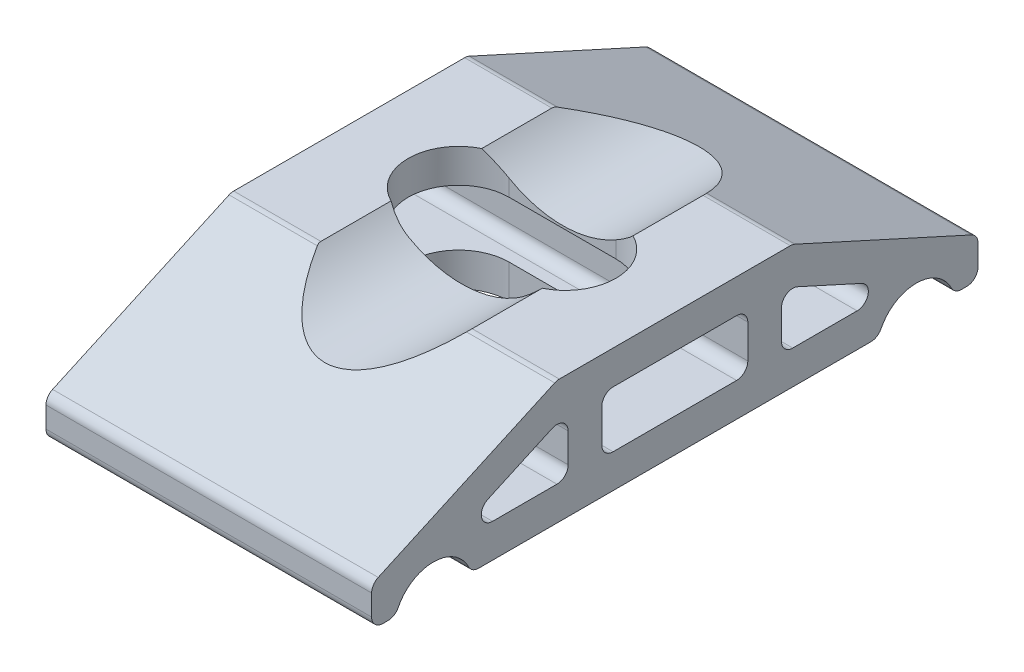
from build123d import *

# Parameters (mm, degrees)
EXTRUSION1_DEPTH             = 14.5
ENL_V_MAT_EXTRU_1_DEPTH      = 12
ESQUISSE3_R                  = 9.5
ENL_V_MAT_EXTRU_4_DEPTH      = 28
ENL_V_MAT_EXTRU_4_DEPTH_BACK = 28


with BuildPart() as part:
    # Esquisse1 → Extrusion1 (new body, symmetric)
    with BuildSketch(Plane(origin=(0, 0, 0), x_dir=(0, 0, -1), z_dir=(1, 0, 0))):
        with BuildLine():
            Line((-27, 1), (-27, 2.85608673))
            ThreePointArc((-27, 2.85608673), (-26.840774329, 3.397472477), (-26.413802944, 3.766453207))
            Line((-26.413802944, 3.766453207), (-10.69719375, 10.910366477))
            ThreePointArc((-10.69719375, 10.910366477), (-10.495090501, 10.977334763), (-10.283390805, 11))
            Line((-10.283390805, 11), (10.283390805, 11))
            ThreePointArc((10.283390805, 11), (10.495090501, 10.977334763), (10.69719375, 10.910366477))
            Line((10.69719375, 10.910366477), (26.413802944, 3.766453207))
            ThreePointArc((26.413802944, 3.766453207), (26.840774329, 3.397472477), (27, 2.85608673))
            Line((27, 2.85608673), (27, 1))
            ThreePointArc((27, 1), (26.707106781, 0.292893219), (26, 0))
            Line((26, 0), (25.531128874, 0))
            ThreePointArc((25.531128874, 0), (25.004082597, 0.150163414), (24.635322458, 0.555555556))
            ThreePointArc((24.635322458, 0.555555556), (21.5, 2.5), (18.364677542, 0.555555556))
            ThreePointArc((18.364677542, 0.555555556), (17.995917403, 0.150163414), (17.468871126, 0))
            Line((17.468871126, 0), (-17.468871126, 0))
            ThreePointArc((-17.468871126, 0), (-17.995917403, 0.150163414), (-18.364677542, 0.555555556))
            ThreePointArc((-18.364677542, 0.555555556), (-21.5, 2.5), (-24.635322458, 0.555555556))
            ThreePointArc((-24.635322458, 0.555555556), (-25.004082597, 0.150163414), (-25.531128874, 0))
            Line((-25.531128874, 0), (-26, 0))
            ThreePointArc((-26, 0), (-26.707106781, 0.292893219), (-27, 1))
        make_face()
        with BuildLine():
            Line((-5.5, 8), (5.5, 8))
            ThreePointArc((5.5, 8), (6.207106781, 7.707106781), (6.5, 7))
            Line((6.5, 7), (6.5, 4))
            ThreePointArc((6.5, 4), (6.207106781, 3.292893219), (5.5, 3))
            Line((5.5, 3), (-5.5, 3))
            ThreePointArc((-5.5, 3), (-6.207106781, 3.292893219), (-6.5, 4))
            Line((-6.5, 4), (-6.5, 7))
            ThreePointArc((-6.5, 7), (-6.207106781, 7.707106781), (-5.5, 8))
        make_face(mode=Mode.SUBTRACT)
        with BuildLine():
            Line((-9.5, 6.606165101), (-9.5, 4))
            ThreePointArc((-9.5, 4), (-9.792893219, 3.292893219), (-10.5, 3))
            Line((-10.5, 3), (-16.233563221, 3))
            ThreePointArc((-16.233563221, 3), (-17.210897984, 3.788300304), (-16.647366165, 4.910366477))
            Line((-16.647366165, 4.910366477), (-10.913802944, 7.516531578))
            ThreePointArc((-10.913802944, 7.516531578), (-9.958614252, 7.446939429), (-9.5, 6.606165101))
        make_face(mode=Mode.SUBTRACT)
        with BuildLine():
            Line((9.5, 6.606165101), (9.5, 4))
            ThreePointArc((9.5, 4), (9.792893219, 3.292893219), (10.5, 3))
            Line((10.5, 3), (16.233563221, 3))
            ThreePointArc((16.233563221, 3), (17.210897984, 3.788300304), (16.647366165, 4.910366477))
            Line((16.647366165, 4.910366477), (10.913802944, 7.516531578))
            ThreePointArc((10.913802944, 7.516531578), (9.958614252, 7.446939429), (9.5, 6.606165101))
        make_face(mode=Mode.SUBTRACT)
    extrude(amount=EXTRUSION1_DEPTH, both=True)

    # Esquisse2 → Enlèv. mat.-Extru.1 (cut, through all)
    with BuildSketch(Plane.XZ):
        with BuildLine():
            Line((-4.75, 4.5), (4.75, 4.5))
            ThreePointArc((4.75, 4.5), (9.25, 0), (4.75, -4.5))
            Line((4.75, -4.5), (-4.75, -4.5))
            ThreePointArc((-4.75, -4.5), (-9.25, 0), (-4.75, 4.5))
        make_face()
    extrude(amount=-ENL_V_MAT_EXTRU_1_DEPTH, mode=Mode.SUBTRACT)

    # Esquisse3 → Enlèv. mat.-Extru.4 (cut, two sides)
    with BuildSketch(Plane.XY) as enl_v_mat_extru_4_sk:
        with Locations((0, 17.7)):
            Circle(ESQUISSE3_R)
    extrude(amount=ENL_V_MAT_EXTRU_4_DEPTH, mode=Mode.SUBTRACT)
    extrude(enl_v_mat_extru_4_sk.sketch, amount=-ENL_V_MAT_EXTRU_4_DEPTH_BACK, mode=Mode.SUBTRACT)


solid = part.part
